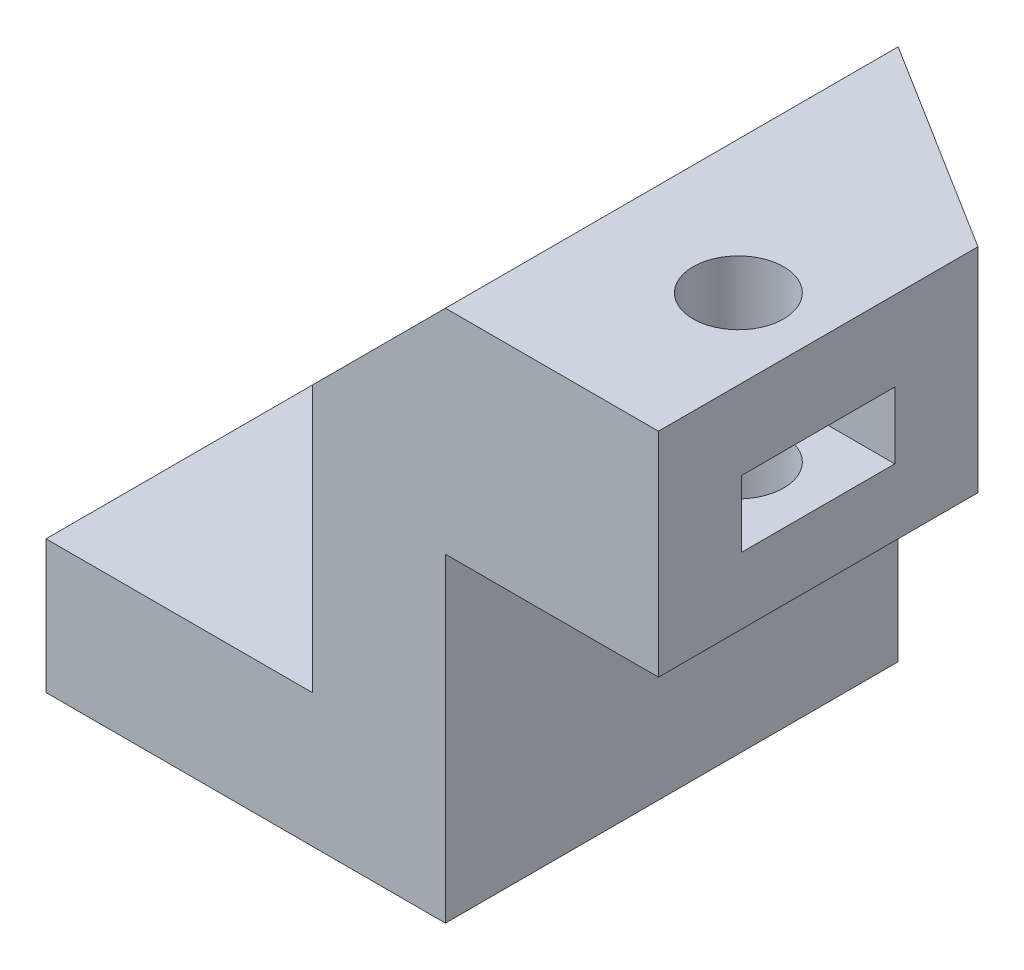
from build123d import *

# Parameters (mm, degrees)
RESSALTO_EXTRUS_O1_DEPTH = 17
ESBO_O2_R                = 2.6
CORTE_EXTRUS_O1_DEPTH    = 20
CHANFRO1_SIZE            = 8
CHANFRO1_SIZE2           = 5
ESBO_O3_R                = 1.7
CORTE_EXTRUS_O2_DEPTH    = 21
CORTE_EXTRUS_O3_START    = -3
CORTE_EXTRUS_O3_DEPTH    = 2.5


with BuildPart() as part:
    # Esboço1 → Ressalto-extrusão1 (new body)
    with BuildSketch(Plane.XY):
        Polygon((0, 0), (15, 0), (15, 12), (23, 12), (23, 20), (15, 20), (10, 15), (10, 5), (0, 5), align=None)
    extrude(amount=-RESSALTO_EXTRUS_O1_DEPTH)

    # Esboço2 → Corte-extrusão1 (cut)
    with BuildSketch(Plane(origin=(0, 5, 0), x_dir=(1, 0, 0), z_dir=(0, 1, 0))):
        with Locations((5, 10)):
            Circle(ESBO_O2_R)
    extrude(amount=-CORTE_EXTRUS_O1_DEPTH, mode=Mode.SUBTRACT)

    # Chanfro1
    chanfro1_edges = [part.edges().sort_by_distance(p)[0] for p in [
        (23, 16, -17),
    ]]
    chanfro1_side = [part.faces().sort_by_distance(p)[0] for p in [
        (12.755169562, 9.52770885, -17),
    ]]
    chamfer(chanfro1_edges, length=CHANFRO1_SIZE, length2=CHANFRO1_SIZE2, reference=chanfro1_side[0])

    # Esboço3 → Corte-extrusão2 (cut, through all)
    with BuildSketch(Plane(origin=(0, 20, 0), x_dir=(1, 0, 0), z_dir=(0, 1, 0))):
        with Locations((20, 6)):
            Circle(ESBO_O3_R)
    extrude(amount=-CORTE_EXTRUS_O2_DEPTH, mode=Mode.SUBTRACT)

    # Esboço4 → Corte-extrusão3 (cut)
    with BuildSketch(Plane(origin=(0, 20, 0), x_dir=(1, 0, 0), z_dir=(0, 1, 0)).offset(CORTE_EXTRUS_O3_START)):
        Polygon((23, 8.875), (18.340117976, 8.875), (16.680235952, 6), (18.340117976, 3.125), (23, 3.125), align=None)
    extrude(amount=-CORTE_EXTRUS_O3_DEPTH, mode=Mode.SUBTRACT)


solid = part.part
